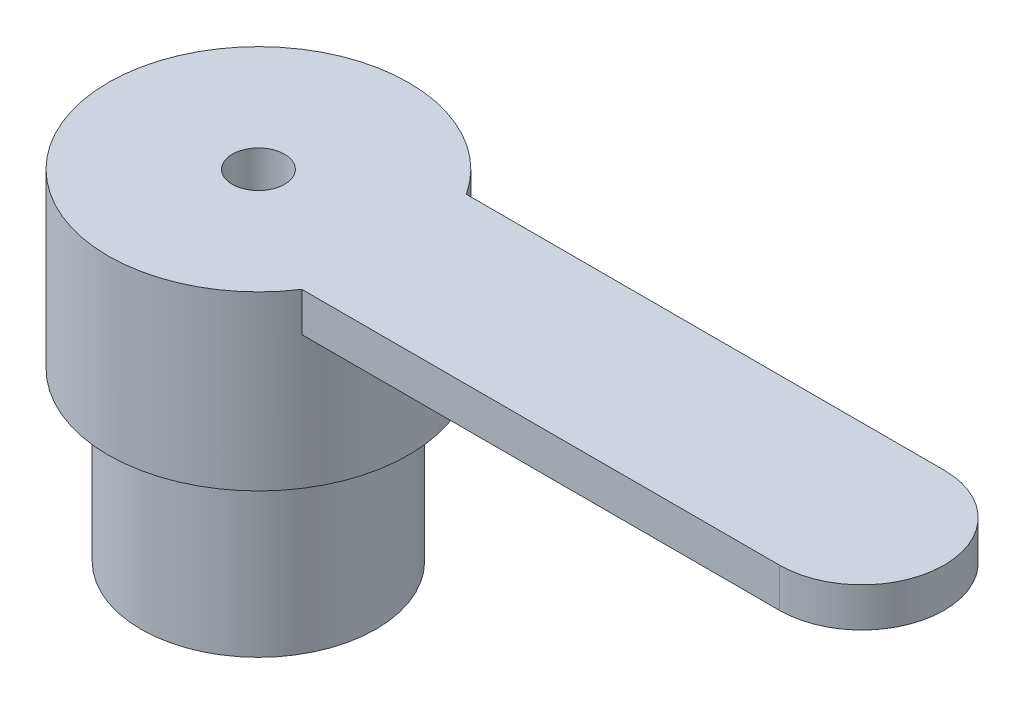
from build123d import *

# Parameters (mm, degrees)
SKETCH1_R           = 2.875
BOSS_EXTRUDE1_DEPTH = 2.55
BOSS_EXTRUDE2_DEPTH = 0.75
SKETCH2_R           = 2.25
BOSS_EXTRUDE3_DEPTH = 3.2
SKETCH3_R           = 0.5
CUT_EXTRUDE1_DEPTH  = 7.5


with BuildPart() as part:
    # Sketch1 → Boss-Extrude1 (new body)
    with BuildSketch(Plane(origin=(0, 0, 0), x_dir=(1, 0, 0), z_dir=(0, 1, 0))):
        Circle(SKETCH1_R)
    extrude(amount=-BOSS_EXTRUDE1_DEPTH)

    # Sketch1_4 → Boss-Extrude2 (add)
    with BuildSketch(Plane(origin=(0, 0, 0), x_dir=(1, 0, 0), z_dir=(0, 1, 0))):
        with BuildLine():
            Line((2.405202694, -1.575), (11.55, -1.575))
            ThreePointArc((11.55, -1.575), (13.125, 0), (11.55, 1.575))
            Line((11.55, 1.575), (2.405202694, 1.575))
            ThreePointArc((2.405202694, 1.575), (-2.875, 0), (2.405202694, -1.575))
        make_face()
    extrude(amount=BOSS_EXTRUDE2_DEPTH)

    # Sketch2 → Boss-Extrude3 (add)
    with BuildSketch(Plane.XZ.offset(2.55)):
        Circle(SKETCH2_R)
    extrude(amount=BOSS_EXTRUDE3_DEPTH)

    # Sketch3 → Cut-Extrude1 (cut, through all)
    with BuildSketch(Plane.XZ.offset(5.75)):
        Circle(SKETCH3_R)
    extrude(amount=-CUT_EXTRUDE1_DEPTH, mode=Mode.SUBTRACT)


solid = part.part
